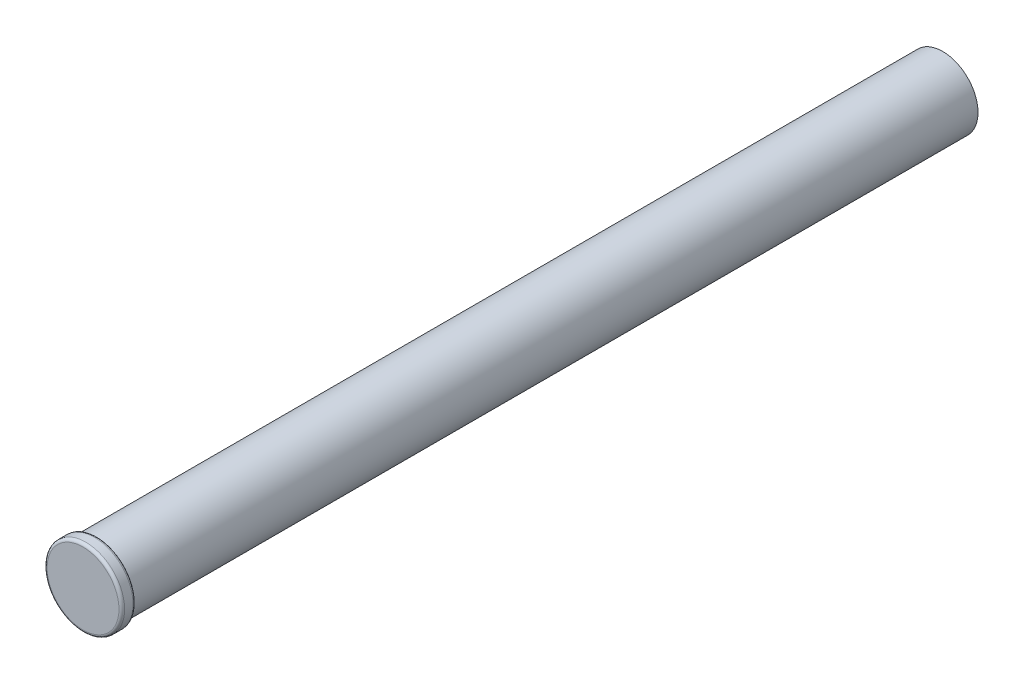
from build123d import *

# Parameters (mm, degrees)
SKETCH2_R           = 1.25
BOSS_EXTRUDE1_DEPTH = 30
SKETCH3_R           = 1.375
BOSS_EXTRUDE2_DEPTH = 0.5
FILLET1_R           = 0.1


with BuildPart() as part:
    # Sketch2 → Boss-Extrude1 (new body)
    with BuildSketch(Plane.XY):
        Circle(SKETCH2_R)
    extrude(amount=BOSS_EXTRUDE1_DEPTH)

    # Sketch3 → Boss-Extrude2 (add)
    with BuildSketch(Plane.XY.offset(30)):
        Circle(SKETCH3_R)
    extrude(amount=BOSS_EXTRUDE2_DEPTH)

    # Fillet1
    fillet1_edges = [part.edges().sort_by_distance(p)[0] for p in [
        (-1.375, 0, 30),
        (-1.375, 0, 30.5),
    ]]
    fillet(fillet1_edges, radius=FILLET1_R)


solid = part.part
